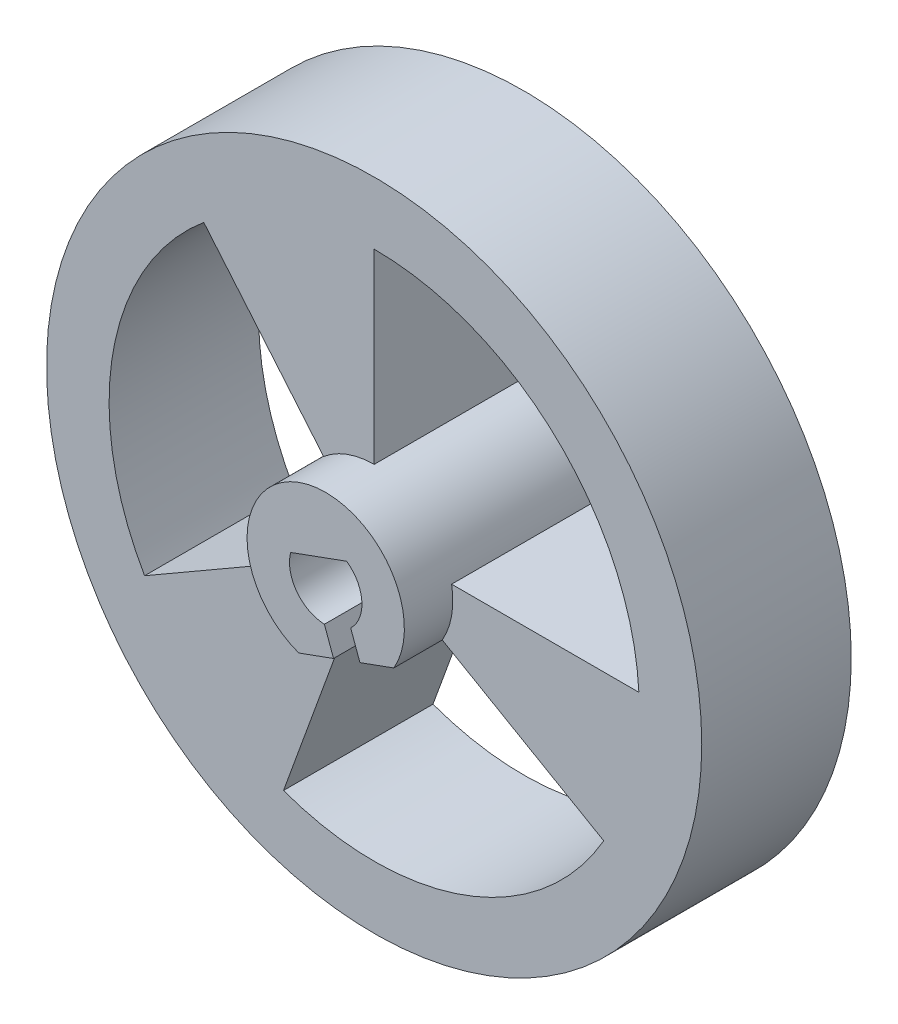
from build123d import *

# Parameters (mm, degrees)
ESQUISSE2_R        = 14.2
BOSS_EXTRU_8_DEPTH = 6.48
BOSS_EXTRU_9_DEPTH = 2.1


with BuildPart() as part:
    # Esquisse2 → Boss.-Extru.8 (new body)
    with BuildSketch(Plane.XY):
        Circle(ESQUISSE2_R)
        with BuildLine():
            Line((1.483428969, -2.23993348), (2.953146627, -1.705))
            Line((2.953146627, -1.705), (9.950631889, -5.745))
            ThreePointArc((9.950631889, -5.745), (3.929811447, -10.797068213), (-3.929811447, -10.797068213))
            Line((-3.929811447, -10.797068213), (-1.166288689, -3.204351837))
            Line((-1.166288689, -3.204351837), (0.339010323, -2.656467803))
            Line((0.339010323, -2.656467803), (-0.017447021, -1.677109299))
            Line((-0.017447021, -1.677109299), (-0.056805783, -1.568971989))
            ThreePointArc((-0.056805783, -1.568971989), (-1.2591971, -0.93772206), (-1.519465743, 0.395125113))
            Line((-1.519465743, 0.395125113), (0.909996763, 1.27937715))
            ThreePointArc((0.909996763, 1.27937715), (1.566031564, 0.111557793), (1.082162789, -1.137463712))
            Line((1.082162789, -1.137463712), (1.126971625, -1.260574976))
            Line((1.126971625, -1.260574976), (1.483428969, -2.23993348))
        make_face(mode=Mode.SUBTRACT)
        with BuildLine():
            Line((-7.385629635, 8.801850651), (-2.191905749, 2.612211551))
            ThreePointArc((-2.191905749, 2.612211551), (-2.953146627, 1.705), (-3.358194438, 0.592140286))
            ThreePointArc((-3.358194438, 0.592140286), (-3.358194438, -0.592140286), (-2.953146627, -1.705))
            Line((-2.953146627, -1.705), (-9.950631889, -5.745))
            ThreePointArc((-9.950631889, -5.745), (-11.315441082, 1.995217561), (-7.385629635, 8.801850651))
        make_face(mode=Mode.SUBTRACT)
        with BuildLine():
            Line((0, 3.41), (0, 11.49))
            ThreePointArc((0, 11.49), (7.912534617, 8.331380194), (11.4747318, 0.592140286))
            Line((11.4747318, 0.592140286), (3.358194438, 0.592140286))
            ThreePointArc((3.358194438, 0.592140286), (2.191905749, 2.612211551), (0, 3.41))
        make_face(mode=Mode.SUBTRACT)
    extrude(amount=BOSS_EXTRU_8_DEPTH)

    # Esquisse6 → Boss.-Extru.9 (add)
    with BuildSketch(Plane.XY.offset(6.48)):
        with BuildLine():
            Line((-1.519465743, 0.395125113), (0.909996763, 1.27937715))
            ThreePointArc((0.909996763, 1.27937715), (1.566031564, 0.111557793), (1.082162789, -1.137463712))
            Line((1.082162789, -1.137463712), (1.483428969, -2.23993348))
            Line((1.483428969, -2.23993348), (2.953146627, -1.705))
            ThreePointArc((2.953146627, -1.705), (-1.166288689, 3.204351837), (-1.166288689, -3.204351837))
            Line((-1.166288689, -3.204351837), (0.339010323, -2.656467803))
            Line((0.339010323, -2.656467803), (-0.056805783, -1.568971989))
            ThreePointArc((-0.056805783, -1.568971989), (-1.2591971, -0.93772206), (-1.519465743, 0.395125113))
        make_face()
    extrude(amount=BOSS_EXTRU_9_DEPTH)


solid = part.part
